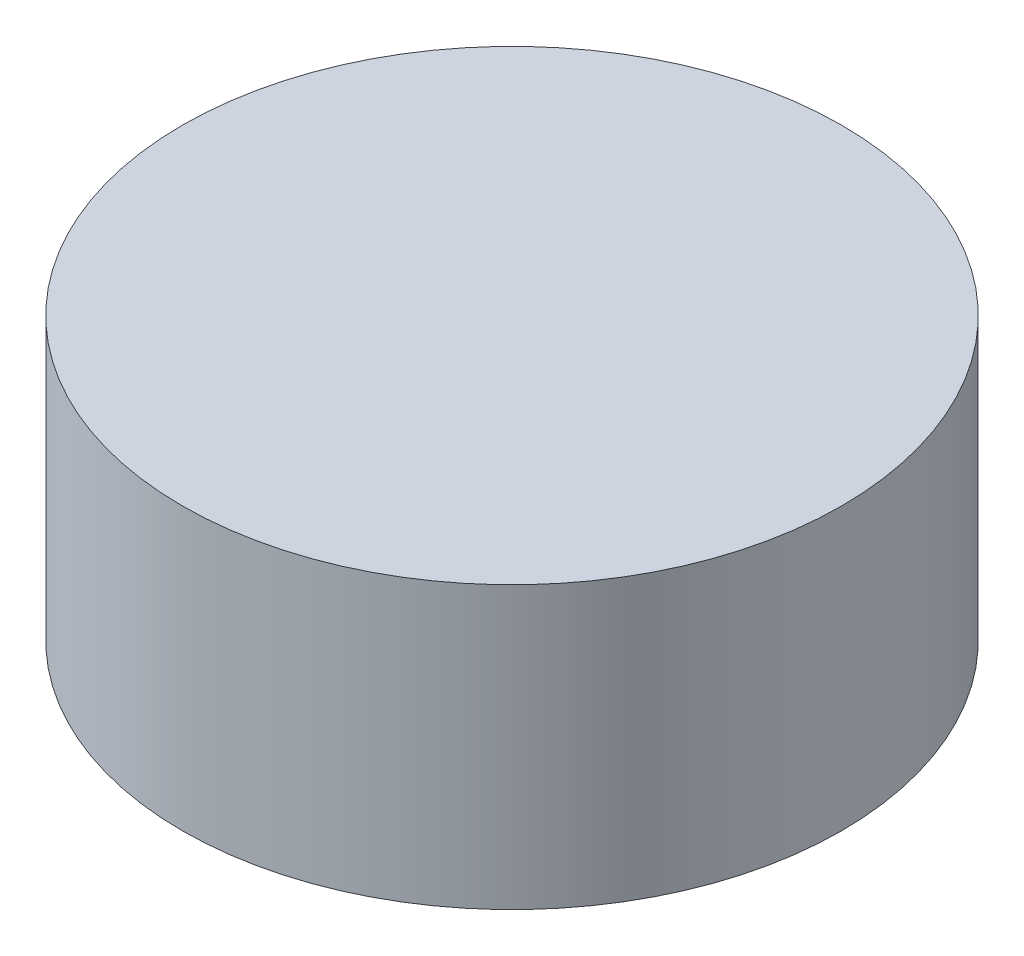
from build123d import *

# Parameters (mm, degrees)
SKETCH1_R           = 9.525
BOSS_EXTRUDE1_DEPTH = 8.128


with BuildPart() as part:
    # Sketch1 → Boss-Extrude1 (new body)
    with BuildSketch(Plane(origin=(0, 0, 0), x_dir=(1, 0, 0), z_dir=(0, 1, 0))):
        Circle(SKETCH1_R)
    extrude(amount=BOSS_EXTRUDE1_DEPTH)


solid = part.part
